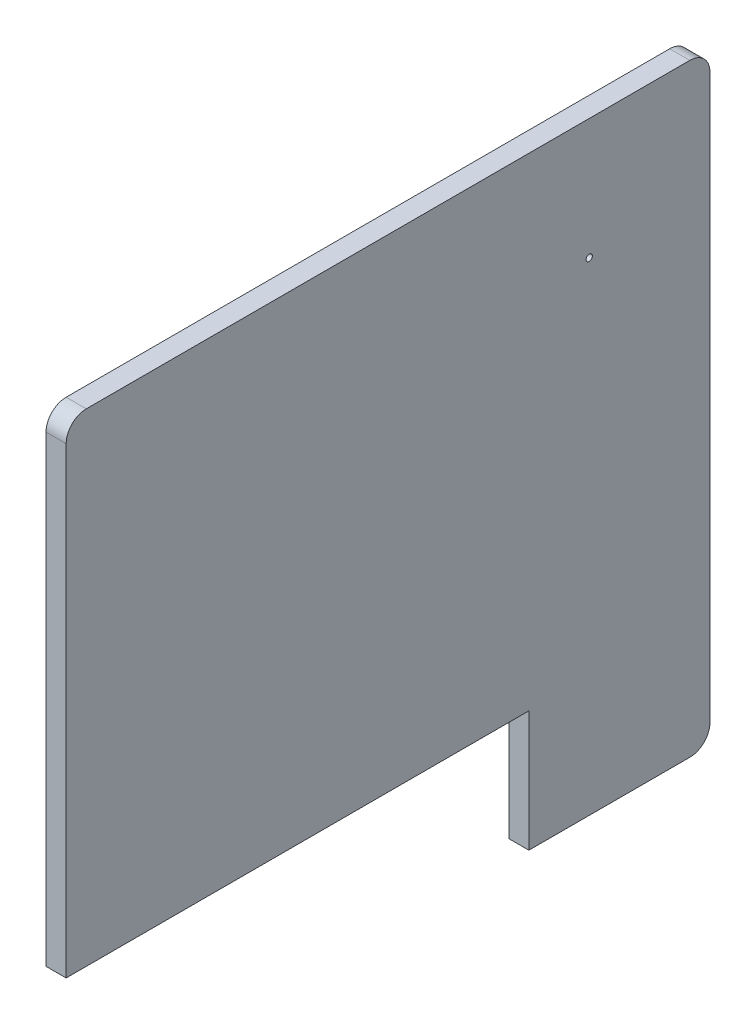
from build123d import *

# Parameters (mm, degrees)
SKETCH1_W           = 101.6
SKETCH1_H           = 95.25
SKETCH1_R           = 0.5
BOSS_EXTRUDE1_DEPTH = 3.175
SKETCH2_W           = 73.025
SKETCH2_H           = 19.05
CUT_EXTRUDE1_DEPTH  = 4.175
FILLET1_R           = 3.175


with BuildPart() as part:
    # Sketch1 → Boss-Extrude1 (new body)
    with BuildSketch(Plane(origin=(0, 0, 0), x_dir=(0, 0, -1), z_dir=(1, 0, 0))):
        with Locations((50.8, 47.625)):
            Rectangle(SKETCH1_W, SKETCH1_H)
        with Locations((82.55, 76.2)):
            Circle(SKETCH1_R, mode=Mode.SUBTRACT)
    extrude(amount=BOSS_EXTRUDE1_DEPTH)

    # Sketch2 → Cut-Extrude1 (cut, through all)
    with BuildSketch(Plane(origin=(3.175, 0, 0), x_dir=(0, 0, -1), z_dir=(1, 0, 0))):
        with Locations((36.5125, 9.525)):
            Rectangle(SKETCH2_W, SKETCH2_H)
    extrude(amount=-CUT_EXTRUDE1_DEPTH, mode=Mode.SUBTRACT)

    # Fillet1
    fillet1_edges = [part.edges().sort_by_distance(p)[0] for p in [
        (1.5875, 95.25, 0),
        (1.5875, 95.25, -101.6),
        (1.5875, 0, -101.6),
    ]]
    fillet(fillet1_edges, radius=FILLET1_R)


solid = part.part
